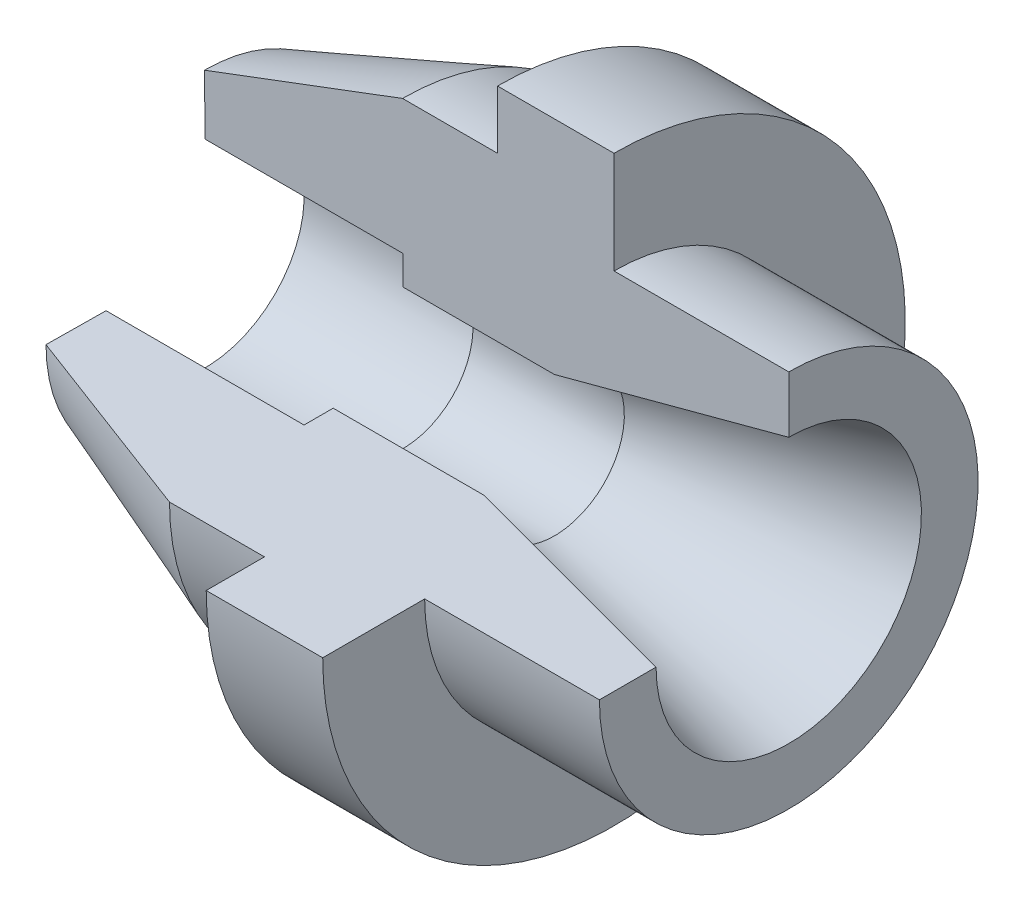
from build123d import *

# Parameters (mm, degrees)
REVOLVE1_ANGLE = 270


with BuildPart() as part:
    # Sketch1 → Revolve1 (revolve)
    with BuildSketch(Plane.XY):
        Polygon((-50, -25), (-50.300177152, 2.198343583), (-16.300177152, 15), (0, 15), (0, 25), (20, 25), (20, 7.5), (50, 7.5), (50, -25), align=None)
    revolve(axis=Axis((50, -25, 0), (-1, 0, 0)), revolution_arc=REVOLVE1_ANGLE)

    # Sketch2 → Cut-Revolve1 (revolve, cut)
    with BuildSketch(Plane.XY):
        Polygon((-50.187622145, -8), (-16.203429147, -8), (-16.203429147, -13), (9.780588509, -13), (50, -2.223241171), (50, -25), (-50.300177152, -25), align=None)
    revolve(axis=Axis((50, -25, 0), (-1, 0, 0)), mode=Mode.SUBTRACT)


solid = part.part
